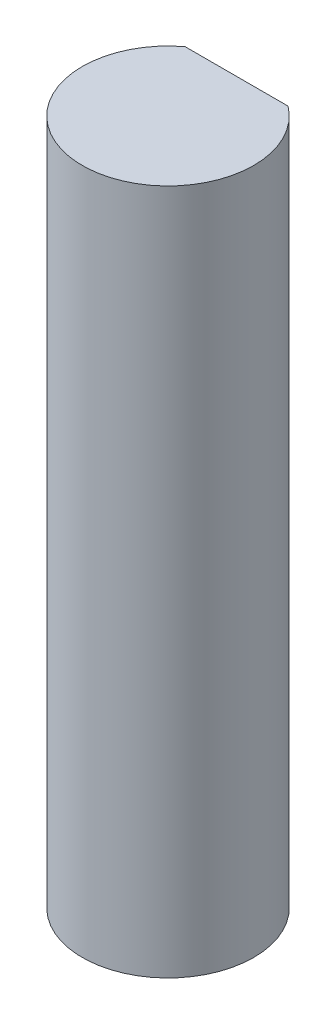
from build123d import *

# Parameters (mm, degrees)
BOSS_EXTRUDE1_DEPTH = 25.4


with BuildPart() as part:
    # Sketch1 → Boss-Extrude1 (new body)
    with BuildSketch(Plane(origin=(0, 0, 0), x_dir=(1, 0, 0), z_dir=(0, 1, 0))):
        with BuildLine():
            Line((-1.905, 2.54), (1.905, 2.54))
            ThreePointArc((1.905, 2.54), (0, -3.175), (-1.905, 2.54))
        make_face()
    extrude(amount=BOSS_EXTRUDE1_DEPTH)


solid = part.part
